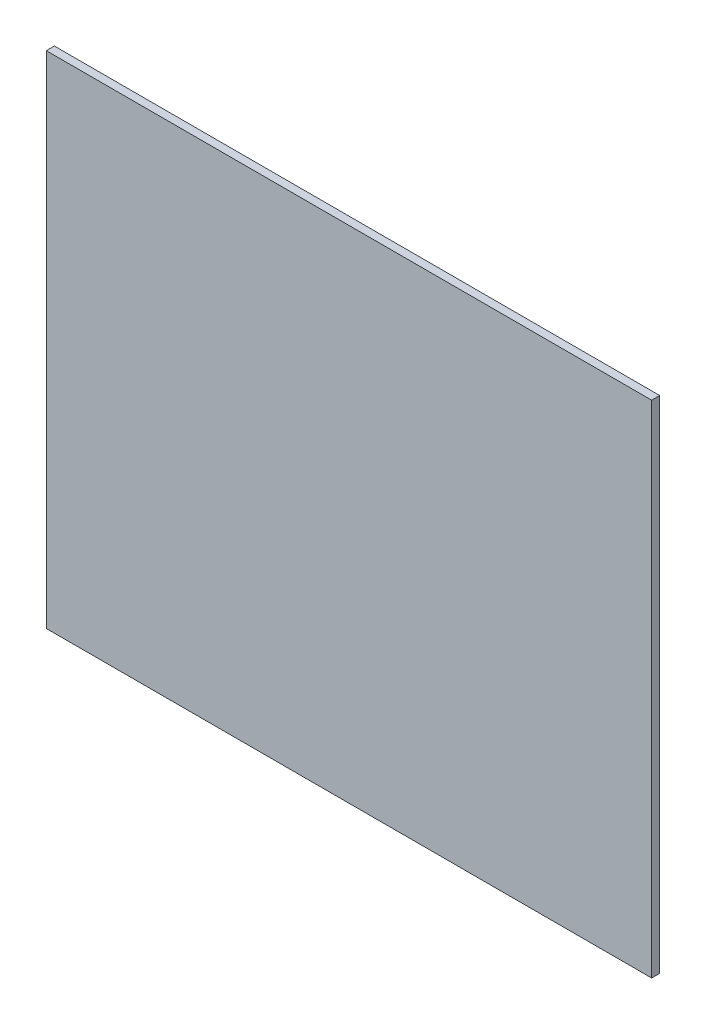
from build123d import *

# Parameters (mm, degrees)
ESQUISSE1_W        = 375
ESQUISSE1_H        = 310
BOSS_EXTRU_1_DEPTH = 5


with BuildPart() as part:
    # Esquisse1 → Boss.-Extru.1 (new body)
    with BuildSketch(Plane.XY):
        with Locations((-187.5, 155)):
            Rectangle(ESQUISSE1_W, ESQUISSE1_H)
    extrude(amount=BOSS_EXTRU_1_DEPTH)


solid = part.part
